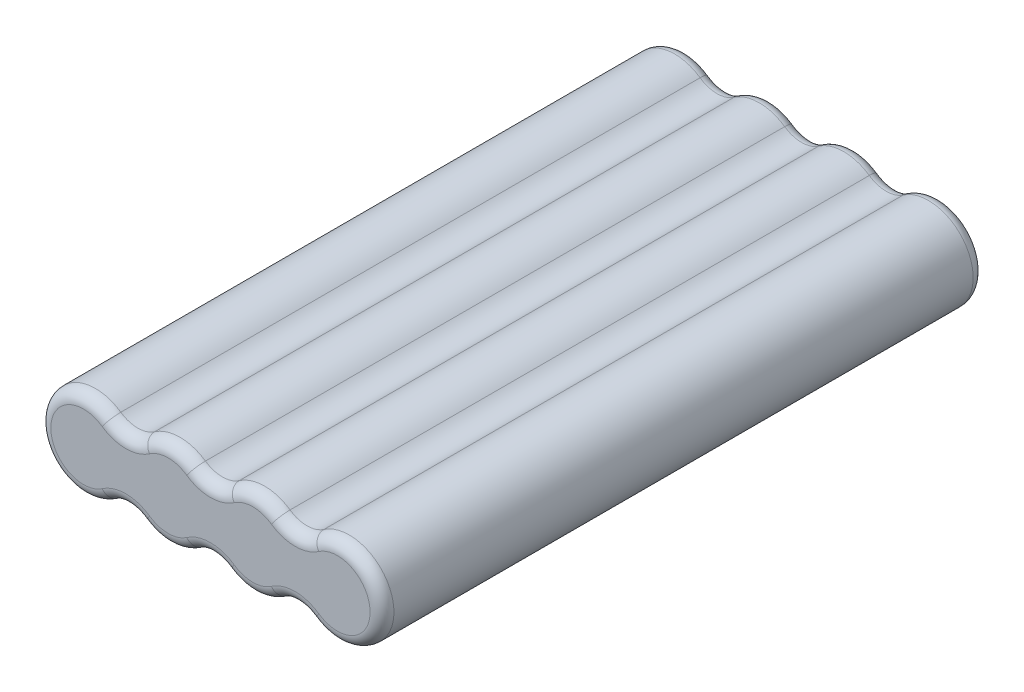
from build123d import *

# Parameters (mm, degrees)
BOSS_EXTRUDE1_DEPTH = 50.673
FILLET1_R           = 2


with BuildPart() as part:
    # Sketch1 → Boss-Extrude1 (new body, symmetric)
    with BuildSketch(Plane.XY):
        with BuildLine():
            ThreePointArc((-17.0632, 6.168707349), (-28.829, 0), (-17.0632, -6.168707349))
            ThreePointArc((-17.0632, -6.168707349), (-14.219333333, -5.281178915), (-11.375466667, -6.168707349))
            ThreePointArc((-11.375466667, -6.168707349), (-7.109666667, -7.5), (-2.843866667, -6.168707349))
            ThreePointArc((-2.843866667, -6.168707349), (0, -5.281178915), (2.843866667, -6.168707349))
            ThreePointArc((2.843866667, -6.168707349), (7.109666667, -7.5), (11.375466667, -6.168707349))
            ThreePointArc((11.375466667, -6.168707349), (14.219333333, -5.281178915), (17.0632, -6.168707349))
            ThreePointArc((17.0632, -6.168707349), (28.829, 0), (17.0632, 6.168707349))
            ThreePointArc((17.0632, 6.168707349), (14.219333333, 5.281178915), (11.375466667, 6.168707349))
            ThreePointArc((11.375466667, 6.168707349), (7.109666667, 7.5), (2.843866667, 6.168707349))
            ThreePointArc((2.843866667, 6.168707349), (0, 5.281178915), (-2.843866667, 6.168707349))
            ThreePointArc((-2.843866667, 6.168707349), (-7.109666667, 7.5), (-11.375466667, 6.168707349))
            ThreePointArc((-11.375466667, 6.168707349), (-14.219333333, 5.281178915), (-17.0632, 6.168707349))
        make_face()
    extrude(amount=BOSS_EXTRUDE1_DEPTH, both=True)

    # Fillet1
    fillet1_edges = [part.edges().sort_by_distance(p)[0] for p in [
        (7.109666667, -7.5, -50.673),
        (0, -5.281178915, -50.673),
        (14.219333333, 5.281178915, 50.673),
        (-7.109666667, -7.5, -50.673),
        (-14.219333333, -5.281178915, -50.673),
        (-28.829, 0, -50.673),
        (-14.219333333, 5.281178915, -50.673),
        (-7.109666667, 7.5, -50.673),
        (0, 5.281178915, -50.673),
        (7.109666667, 7.5, -50.673),
        (14.219333333, 5.281178915, -50.673),
        (28.829, 0, -50.673),
        (14.219333333, -5.281178915, -50.673),
        (7.109666667, 7.5, 50.673),
        (0, 5.281178915, 50.673),
        (-7.109666667, 7.5, 50.673),
        (-14.219333333, 5.281178915, 50.673),
        (-28.829, 0, 50.673),
        (-14.219333333, -5.281178915, 50.673),
        (-7.109666667, -7.5, 50.673),
        (0, -5.281178915, 50.673),
        (7.109666667, -7.5, 50.673),
        (14.219333333, -5.281178915, 50.673),
        (28.829, 0, 50.673),
    ]]
    fillet(fillet1_edges, radius=FILLET1_R)


solid = part.part
